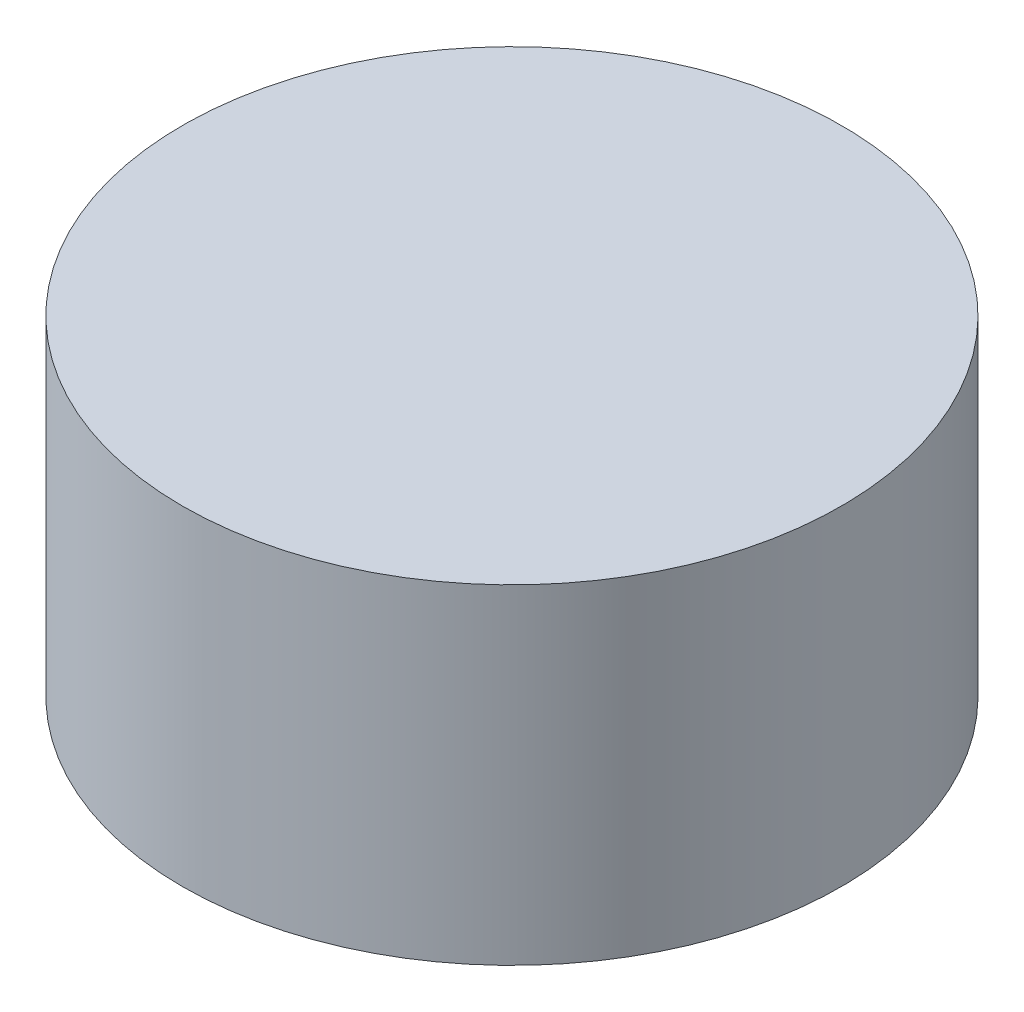
from build123d import *

# Parameters (mm, degrees)
SKETCH1_R           = 1.5
BOSS_EXTRUDE1_DEPTH = 1.5


with BuildPart() as part:
    # Sketch1 → Boss-Extrude1 (new body)
    with BuildSketch(Plane(origin=(0, 0, 0), x_dir=(1, 0, 0), z_dir=(0, 1, 0))):
        Circle(SKETCH1_R)
    extrude(amount=BOSS_EXTRUDE1_DEPTH)


solid = part.part
